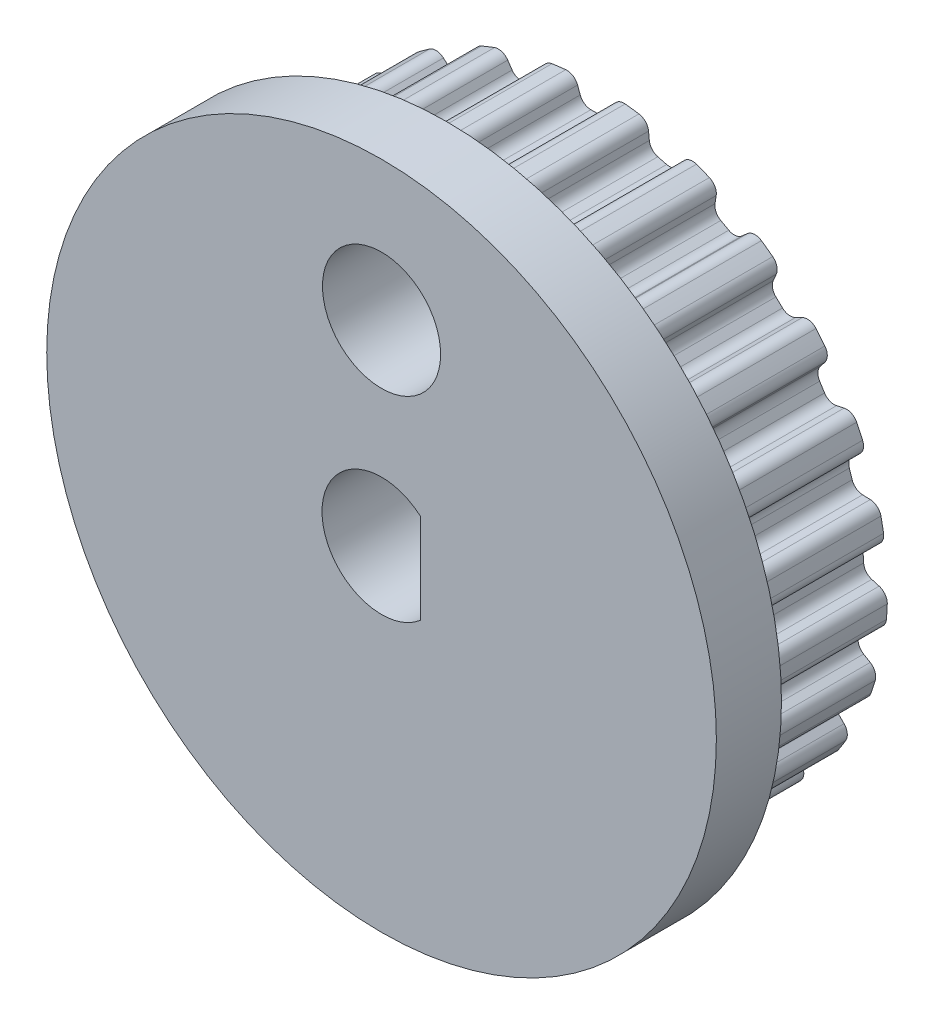
from build123d import *

# Parameters (mm, degrees)
BOSS_EXTRUDE1_DEPTH = 4.000000001
SKETCH2_R           = 9
BOSS_EXTRUDE2_DEPTH = 1.75
SKETCH4_W           = 4.5
SKETCH4_H           = 4.5
BOSS_EXTRUDE3_DEPTH = 1.75
CUT_EXTRUDE2_DEPTH  = 8.500000001
SKETCH5_R           = 1.5875
CUT_EXTRUDE3_DEPTH  = 8.500000001


with BuildPart() as part:
    # Sketch1 → Boss-Extrude1 (new body)
    with BuildSketch(Plane(origin=(0, 0, -5.299999992), x_dir=(-1, 0, 0), z_dir=(0, 0, -1))):
        with BuildLine():
            Line((-2.770498963, -6.663011251), (-2.541538281, -6.753663208))
            ThreePointArc((-2.541538281, -6.753663208), (-2.399281022, -6.869272551), (-2.349061487, -7.04556959))
            Line((-2.349061487, -7.04556959), (-2.354850369, -7.252814955))
            ThreePointArc((-2.354850369, -7.252814955), (-2.295763451, -7.44184279), (-2.13298896, -7.55465791))
            ThreePointArc((-2.13298896, -7.55465791), (-1.9522156, -7.60337769), (-1.770331764, -7.647772452))
            ThreePointArc((-1.770331764, -7.647772452), (-1.573342284, -7.627329016), (-1.430499165, -7.490147994))
            Line((-1.430499165, -7.490147994), (-1.335730789, -7.305748684))
            ThreePointArc((-1.335730789, -7.305748684), (-1.206791332, -7.175451857), (-1.026435123, -7.142675578))
            Line((-1.026435123, -7.142675578), (-0.782123427, -7.173539321))
            ThreePointArc((-0.782123427, -7.173539321), (-0.615584572, -7.250138629), (-0.523099481, -7.408407869))
            Line((-0.523099481, -7.408407869), (-0.477166643, -7.610581923))
            ThreePointArc((-0.477166643, -7.610581923), (-0.372926733, -7.778976773), (-0.187210126, -7.847767225))
            ThreePointArc((-0.187210126, -7.847767225), (1.8e-08, -7.849999876), (0.187210163, -7.847767225))
            ThreePointArc((0.187210163, -7.847767225), (0.372926769, -7.778976773), (0.477166678, -7.610581924))
            Line((0.477166678, -7.610581924), (0.523099513, -7.408407881))
            ThreePointArc((0.523099513, -7.408407881), (0.615584602, -7.250138644), (0.782123452, -7.173539334))
            Line((0.782123452, -7.173539334), (1.026435157, -7.142675586))
            ThreePointArc((1.026435157, -7.142675586), (1.206791369, -7.175451863), (1.33573083, -7.305748691))
            Line((1.33573083, -7.305748691), (1.430499202, -7.490147994))
            ThreePointArc((1.430499202, -7.490147994), (1.573342321, -7.627329016), (1.770331801, -7.647772452))
            ThreePointArc((1.770331801, -7.647772452), (1.952215637, -7.60337769), (2.132988997, -7.55465791))
            ThreePointArc((2.132988997, -7.55465791), (2.295763494, -7.441842782), (2.354850406, -7.252814935))
            Line((2.354850406, -7.252814935), (2.349061514, -7.045569606))
            ThreePointArc((2.349061514, -7.045569606), (2.399281043, -6.869272556), (2.541538305, -6.753663204))
            Line((2.541538305, -6.753663204), (2.770498989, -6.663011244))
            ThreePointArc((2.770498989, -6.663011244), (2.953340111, -6.64990502), (3.11063221, -6.744042389))
            Line((3.11063221, -6.744042389), (3.248281539, -6.899080544))
            ThreePointArc((3.248281539, -6.899080544), (3.42075251, -6.996428125), (3.616637274, -6.967240001))
            ThreePointArc((3.616637274, -6.967240001), (3.781766365, -6.879007311), (3.94474428, -6.786861647))
            ThreePointArc((3.94474428, -6.786861647), (4.074348937, -6.637110438), (4.084570207, -6.439326927))
            Line((4.084570207, -6.439326927), (4.027423359, -6.240032231))
            ThreePointArc((4.027423359, -6.240032231), (4.032221853, -6.056784784), (4.141258967, -5.909429568))
            Line((4.141258967, -5.909429568), (4.340482222, -5.76468539))
            ThreePointArc((4.340482222, -5.76468539), (4.514319692, -5.706520185), (4.690081199, -5.758583127))
            Line((4.690081199, -5.758583127), (4.861962355, -5.874518455))
            ThreePointArc((4.861962355, -5.874518455), (5.053224205, -5.925915922), (5.235696117, -5.848930236))
            ThreePointArc((5.235696117, -5.848930236), (5.373694804, -5.722403597), (5.50863678, -5.592621893))
            ThreePointArc((5.50863678, -5.592621893), (5.596928058, -5.415344021), (5.557641445, -5.221232311))
            Line((5.557641445, -5.221232311), (5.452727407, -5.042410696))
            ThreePointArc((5.452727407, -5.042410696), (5.411803358, -4.863726966), (5.480769122, -4.693884755))
            Line((5.480769122, -4.693884755), (5.637737001, -4.504143178))
            ThreePointArc((5.637737001, -4.504143178), (5.791647936, -4.404573728), (5.974835084, -4.411290898))
            Line((5.974835084, -4.411290898), (6.170148257, -4.480838795))
            ThreePointArc((6.170148257, -4.480838795), (6.368183279, -4.483056618), (6.525776925, -4.363110665))
            ThreePointArc((6.525776925, -4.363110665), (6.627974228, -4.206240225), (6.726401351, -4.046977156))
            ThreePointArc((6.726401351, -4.046977156), (6.767831585, -3.853311658), (6.681505632, -3.675068511))
            Line((6.681505632, -3.675068511), (6.535416505, -3.527955909))
            ThreePointArc((6.535416505, -3.527955909), (6.451341341, -3.365063263), (6.475902375, -3.183405886))
            Line((6.475902375, -3.183405886), (6.580751989, -2.960589078))
            ThreePointArc((6.580751989, -2.960589078), (6.705065617, -2.825871679), (6.884168106, -2.78682102))
            Line((6.884168106, -2.78682102), (7.090641024, -2.805611531))
            ThreePointArc((7.090641024, -2.805611531), (7.283005966, -2.758510368), (7.405819176, -2.603140787))
            ThreePointArc((7.405819176, -2.603140787), (7.46579367, -2.425783284), (7.52152141, -2.247045927))
            ThreePointArc((7.52152141, -2.247045927), (7.513487384, -2.049161499), (7.385546242, -1.897986579))
            Line((7.385546242, -1.897986579), (7.207461372, -1.791826697))
            ThreePointArc((7.207461372, -1.791826697), (7.085517816, -1.654960251), (7.06413088, -1.472901871))
            Line((7.06413088, -1.472901871), (7.110274201, -1.231010202))
            ThreePointArc((7.110274201, -1.231010202), (7.197179435, -1.069609688), (7.360943563, -0.987244916))
            Line((7.360943563, -0.987244916), (7.565602753, -0.95409736))
            ThreePointArc((7.565602753, -0.95409736), (7.740210608, -0.86063675), (7.820526569, -0.679605993))
            ThreePointArc((7.820526569, -0.679605993), (7.834509837, -0.492905448), (7.844036614, -0.305924525))
            ThreePointArc((7.844036614, -0.305924525), (7.78704314, -0.116254991), (7.625525841, -0.001647178))
            Line((7.625525841, -0.001647178), (7.426634918, 0.056889606))
            ThreePointArc((7.426634918, 0.056889606), (7.274485151, 0.15913001), (7.208494045, 0.330149967))
            Line((7.208494045, 0.330149967), (7.193031666, 0.575917525))
            ThreePointArc((7.193031666, 0.575917525), (7.237067931, 0.753859804), (7.375203825, 0.874363422))
            Line((7.375203825, 0.874363422), (7.565189822, 0.957366261))
            ThreePointArc((7.565189822, 0.957366261), (7.711069345, 1.091313843), (7.743841513, 1.286630957))
            ThreePointArc((7.743841513, 1.286630957), (7.710954935, 1.470943449), (7.673682148, 1.654419227))
            ThreePointArc((7.673682148, 1.654419227), (7.571310327, 1.82395625), (7.386365577, 1.894795725))
            Line((7.386365577, 1.894795725), (7.179165715, 1.902031296))
            ThreePointArc((7.179165715, 1.902031296), (7.006369859, 1.963221511), (6.899921047, 2.112457233))
            Line((6.899921047, 2.112457233), (6.823824527, 2.346658216))
            ThreePointArc((6.823824527, 2.346658216), (6.822224861, 2.529961496), (6.926052937, 2.681032281))
            Line((6.926052937, 2.681032281), (7.089428199, 2.808675019))
            ThreePointArc((7.089428199, 2.808675019), (7.197413244, 2.974693155), (7.180582424, 3.172024133))
            ThreePointArc((7.180582424, 3.172024133), (7.10289238, 3.342367562), (7.02116201, 3.510809758))
            ThreePointArc((7.02116201, 3.510809758), (6.879844249, 3.649561624), (6.683092823, 3.67218166))
            Line((6.683092823, 3.67218166), (6.480603082, 3.627661399))
            ThreePointArc((6.480603082, 3.627661399), (6.298018541, 3.643956633), (6.157800604, 3.762031099))
            Line((6.157800604, 3.762031099), (6.025851382, 3.969949803))
            ThreePointArc((6.025851382, 3.969949803), (5.978716304, 4.147096461), (6.041712663, 4.319242076))
            Line((6.041712663, 4.319242076), (6.168211718, 4.483504424))
            ThreePointArc((6.168211718, 4.483504424), (6.231517191, 4.671161588), (6.166140924, 4.858107403))
            ThreePointArc((6.166140924, 4.858107403), (6.048528974, 5.003778443), (5.927476451, 5.146603192))
            ThreePointArc((5.927476451, 5.146603192), (5.756092274, 5.245851614), (5.559896791, 5.218830927))
            Line((5.559896791, 5.218830927), (5.374840317, 5.125352196))
            ThreePointArc((5.374840317, 5.125352196), (5.193939557, 5.095728573), (5.028762915, 5.175222731))
            Line((5.028762915, 5.175222731), (4.849251859, 5.343794843))
            ThreePointArc((4.849251859, 5.343794843), (4.759543042, 5.50365408), (4.777749369, 5.686057966))
            Line((4.777749369, 5.686057966), (4.859423838, 5.876618788))
            ThreePointArc((4.859423838, 5.876618788), (4.874072, 6.074123776), (4.764258119, 6.238937914))
            ThreePointArc((4.764258119, 6.238937914), (4.614114251, 6.350783528), (4.461345743, 6.459016637))
            ThreePointArc((4.461345743, 6.459016637), (4.270663826, 6.512525475), (4.087351951, 6.437561846))
            Line((4.087351951, 6.437561846), (3.931356637, 6.300998273))
            ThreePointArc((3.931356637, 6.300998273), (3.763506296, 6.227317127), (3.583749576, 6.263236065))
            Line((3.583749576, 6.263236065), (3.367956, 6.381869588))
            ThreePointArc((3.367956, 6.381869588), (3.241310171, 6.514396877), (3.213582509, 6.69559794))
            Line((3.213582509, 6.69559794), (3.245300476, 6.900483573))
            ThreePointArc((3.245300476, 6.900483573), (3.210370947, 7.095426422), (3.063019466, 7.227753016))
            ThreePointArc((3.063019466, 7.227753016), (2.889777761, 7.298745536), (2.714892269, 7.365586324))
            ThreePointArc((2.714892269, 7.365586324), (2.516893872, 7.369993419), (2.357983776, 7.251797104))
            Line((2.357983776, 7.251797104), (2.240851316, 7.080729469))
            ThreePointArc((2.240851316, 7.080729469), (2.096598059, 6.967620471), (1.913556053, 6.957707268))
            Line((1.913556053, 6.957707268), (1.675039076, 7.018948014))
            ThreePointArc((1.675039076, 7.018948014), (1.51941385, 7.115816183), (1.447494432, 7.284428907))
            Line((1.447494432, 7.284428907), (1.427262951, 7.490765576))
            ThreePointArc((1.427262951, 7.490765576), (1.344950483, 7.670897333), (1.169320022, 7.762421829))
            ThreePointArc((1.169320022, 7.762421829), (0.983865903, 7.788100529), (0.797852133, 7.809349137))
            ThreePointArc((0.797852133, 7.809349137), (0.604978216, 7.764377573), (0.480454802, 7.610375273))
            Line((0.480454802, 7.610375273), (0.409545077, 7.415552396))
            ThreePointArc((0.409545077, 7.415552396), (0.297952865, 7.270122591), (0.123126767, 7.215000134))
            Line((0.123126767, 7.215000134), (-0.12312673, 7.215000134))
            ThreePointArc((-0.12312673, 7.215000134), (-0.297952827, 7.270122591), (-0.409545038, 7.415552395))
            Line((-0.409545038, 7.415552395), (-0.480454763, 7.610375271))
            ThreePointArc((-0.480454763, 7.610375271), (-0.604978178, 7.764377573), (-0.797852096, 7.809349137))
            ThreePointArc((-0.797852096, 7.809349137), (-0.983865866, 7.788100529), (-1.169319985, 7.762421829))
            ThreePointArc((-1.169319985, 7.762421829), (-1.344950446, 7.670897333), (-1.427262914, 7.490765576))
            Line((-1.427262914, 7.490765576), (-1.447494396, 7.284428898))
            ThreePointArc((-1.447494396, 7.284428898), (-1.519413814, 7.115816175), (-1.67503904, 7.018948005))
            Line((-1.67503904, 7.018948005), (-1.913556012, 6.957707261))
            ThreePointArc((-1.913556012, 6.957707261), (-2.096598018, 6.967620464), (-2.240851274, 7.080729462))
            Line((-2.240851274, 7.080729462), (-2.357983739, 7.251797104))
            ThreePointArc((-2.357983739, 7.251797104), (-2.516893836, 7.369993419), (-2.714892233, 7.365586324))
            ThreePointArc((-2.714892233, 7.365586324), (-2.889777725, 7.298745536), (-3.063019429, 7.227753016))
            ThreePointArc((-3.063019429, 7.227753016), (-3.210370911, 7.095426422), (-3.24530044, 6.900483573))
            Line((-3.24530044, 6.900483573), (-3.21358247, 6.695597928))
            ThreePointArc((-3.21358247, 6.695597928), (-3.241310132, 6.514396865), (-3.367955962, 6.381869576))
            Line((-3.367955962, 6.381869576), (-3.58374953, 6.263236057))
            ThreePointArc((-3.58374953, 6.263236057), (-3.76350625, 6.227317119), (-3.931356591, 6.300998266))
            Line((-3.931356591, 6.300998266), (-4.087351915, 6.437561846))
            ThreePointArc((-4.087351915, 6.437561846), (-4.27066379, 6.512525475), (-4.461345707, 6.459016637))
            ThreePointArc((-4.461345707, 6.459016637), (-4.614114214, 6.350783528), (-4.764258082, 6.238937914))
            ThreePointArc((-4.764258082, 6.238937914), (-4.874071964, 6.074123776), (-4.859423801, 5.876618788))
            Line((-4.859423801, 5.876618788), (-4.77774934, 5.686057982))
            ThreePointArc((-4.77774934, 5.686057982), (-4.759543013, 5.503654097), (-4.849251829, 5.343794859))
            Line((-4.849251829, 5.343794859), (-5.028762894, 5.17522274))
            ThreePointArc((-5.028762894, 5.17522274), (-5.193939536, 5.095728582), (-5.374840296, 5.125352204))
            Line((-5.374840296, 5.125352204), (-5.559896754, 5.218830927))
            ThreePointArc((-5.559896754, 5.218830927), (-5.756092237, 5.245851614), (-5.927476414, 5.146603192))
            ThreePointArc((-5.927476414, 5.146603192), (-6.048528938, 5.003778443), (-6.166140887, 4.858107403))
            ThreePointArc((-6.166140887, 4.858107403), (-6.231517154, 4.671161588), (-6.168211682, 4.483504424))
            Line((-6.168211682, 4.483504424), (-6.04171263, 4.31924208))
            ThreePointArc((-6.04171263, 4.31924208), (-5.978716271, 4.147096465), (-6.025851349, 3.969949807))
            Line((-6.025851349, 3.969949807), (-6.157800573, 3.7620311))
            ThreePointArc((-6.157800573, 3.7620311), (-6.29801851, 3.643956634), (-6.480603051, 3.6276614))
            Line((-6.480603051, 3.6276614), (-6.683092787, 3.67218166))
            ThreePointArc((-6.683092787, 3.67218166), (-6.879844213, 3.649561624), (-7.021161973, 3.510809758))
            ThreePointArc((-7.021161973, 3.510809758), (-7.102892344, 3.342367562), (-7.180582387, 3.172024133))
            ThreePointArc((-7.180582387, 3.172024133), (-7.197413207, 2.974693155), (-7.089428162, 2.808675019))
            Line((-7.089428162, 2.808675019), (-6.926052897, 2.681032278))
            ThreePointArc((-6.926052897, 2.681032278), (-6.822224821, 2.529961494), (-6.823824488, 2.346658214))
            Line((-6.823824488, 2.346658214), (-6.899921006, 2.112457233))
            ThreePointArc((-6.899921006, 2.112457233), (-7.006369819, 1.963221511), (-7.179165675, 1.902031296))
            Line((-7.179165675, 1.902031296), (-7.386365541, 1.894795725))
            ThreePointArc((-7.386365541, 1.894795725), (-7.571310291, 1.82395625), (-7.673682111, 1.654419227))
            ThreePointArc((-7.673682111, 1.654419227), (-7.710954911, 1.470943384), (-7.743841498, 1.286630826))
            ThreePointArc((-7.743841498, 1.286630826), (-7.711069328, 1.091313715), (-7.565189806, 0.957366136))
            Line((-7.565189806, 0.957366136), (-7.375203809, 0.874363296))
            ThreePointArc((-7.375203809, 0.874363296), (-7.237067915, 0.753859678), (-7.19303165, 0.5759174))
            Line((-7.19303165, 0.5759174), (-7.20849403, 0.330149843))
            ThreePointArc((-7.20849403, 0.330149843), (-7.274485135, 0.159129886), (-7.426634903, 0.056889483))
            Line((-7.426634903, 0.056889483), (-7.6255258, -0.001647294))
            ThreePointArc((-7.6255258, -0.001647294), (-7.7870431, -0.116255109), (-7.844036572, -0.305924646))
            ThreePointArc((-7.844036572, -0.305924646), (-7.834509796, -0.492905509), (-7.820526532, -0.679605993))
            ThreePointArc((-7.820526532, -0.679605993), (-7.740210572, -0.86063675), (-7.565602716, -0.95409736))
            Line((-7.565602716, -0.95409736), (-7.360943526, -0.987244916))
            ThreePointArc((-7.360943526, -0.987244916), (-7.197179397, -1.069609688), (-7.110274163, -1.231010202))
            Line((-7.110274163, -1.231010202), (-7.064130842, -1.47290187))
            ThreePointArc((-7.064130842, -1.47290187), (-7.085517778, -1.654960251), (-7.207461334, -1.791826697))
            Line((-7.207461334, -1.791826697), (-7.385546205, -1.897986579))
            ThreePointArc((-7.385546205, -1.897986579), (-7.513487347, -2.049161499), (-7.521521373, -2.247045927))
            ThreePointArc((-7.521521373, -2.247045927), (-7.465793634, -2.425783284), (-7.405819139, -2.603140787))
            ThreePointArc((-7.405819139, -2.603140787), (-7.28300593, -2.758510368), (-7.090640987, -2.805611531))
            Line((-7.090640987, -2.805611531), (-6.884168079, -2.786821021))
            ThreePointArc((-6.884168079, -2.786821021), (-6.705065589, -2.82587168), (-6.580751962, -2.960589079))
            Line((-6.580751962, -2.960589079), (-6.475902344, -3.183405892))
            ThreePointArc((-6.475902344, -3.183405892), (-6.451341311, -3.36506327), (-6.535416475, -3.527955915))
            Line((-6.535416475, -3.527955915), (-6.681505595, -3.675068511))
            ThreePointArc((-6.681505595, -3.675068511), (-6.767831549, -3.853311658), (-6.726401314, -4.046977156))
            ThreePointArc((-6.726401314, -4.046977156), (-6.627974191, -4.206240225), (-6.525776888, -4.363110665))
            ThreePointArc((-6.525776888, -4.363110665), (-6.368183242, -4.483056618), (-6.17014822, -4.480838795))
            Line((-6.17014822, -4.480838795), (-5.974835047, -4.411290898))
            ThreePointArc((-5.974835047, -4.411290898), (-5.791647899, -4.404573728), (-5.637736963, -4.504143178))
            Line((-5.637736963, -4.504143178), (-5.480769085, -4.693884754))
            ThreePointArc((-5.480769085, -4.693884754), (-5.411803321, -4.863726965), (-5.45272737, -5.042410695))
            Line((-5.45272737, -5.042410695), (-5.557641409, -5.221232311))
            ThreePointArc((-5.557641409, -5.221232311), (-5.596928022, -5.415344021), (-5.508636743, -5.592621893))
            ThreePointArc((-5.508636743, -5.592621893), (-5.373694767, -5.722403597), (-5.235696081, -5.848930236))
            ThreePointArc((-5.235696081, -5.848930236), (-5.053224168, -5.925915922), (-4.861962318, -5.874518455))
            Line((-4.861962318, -5.874518455), (-4.690081172, -5.758583134))
            ThreePointArc((-4.690081172, -5.758583134), (-4.514319665, -5.706520192), (-4.340482195, -5.764685397))
            Line((-4.340482195, -5.764685397), (-4.141258934, -5.909429579))
            ThreePointArc((-4.141258934, -5.909429579), (-4.032221819, -6.056784796), (-4.027423326, -6.240032243))
            Line((-4.027423326, -6.240032243), (-4.08457017, -6.439326927))
            ThreePointArc((-4.08457017, -6.439326927), (-4.0743489, -6.637110438), (-3.944744243, -6.786861647))
            ThreePointArc((-3.944744243, -6.786861647), (-3.781766328, -6.879007311), (-3.616637238, -6.967240001))
            ThreePointArc((-3.616637238, -6.967240001), (-3.420752473, -6.996428125), (-3.248281502, -6.899080544))
            Line((-3.248281502, -6.899080544), (-3.110632181, -6.744042398))
            ThreePointArc((-3.110632181, -6.744042398), (-2.953340083, -6.649905029), (-2.770498963, -6.663011251))
        make_face()
    extrude(amount=-BOSS_EXTRUDE1_DEPTH)

    # Sketch2 → Boss-Extrude2 (add)
    with BuildSketch(Plane.XY.offset(-1.299999991)):
        Circle(SKETCH2_R)
    extrude(amount=BOSS_EXTRUDE2_DEPTH)

    # Sketch4 → Boss-Extrude3 (add)
    with BuildSketch(Plane(origin=(0, 0, -5.299999992), x_dir=(-1, 0, 0), z_dir=(0, 0, -1))):
        Rectangle(SKETCH4_W, SKETCH4_H)
    extrude(amount=BOSS_EXTRUDE3_DEPTH)

    # Sketch3 → Cut-Extrude2 (cut, through all)
    with BuildSketch(Plane.XY.offset(0.450000009)):
        with BuildLine():
            Line((1.041610738, 1.214515158), (1.041610738, -1.214515158))
            ThreePointArc((1.041610738, -1.214515158), (-1.6, 0), (1.041610738, 1.214515158))
        make_face()
    extrude(amount=-CUT_EXTRUDE2_DEPTH, mode=Mode.SUBTRACT)

    # Sketch5 → Cut-Extrude3 (cut, through all)
    with BuildSketch(Plane.XY.offset(0.450000009)):
        with Locations((0, 5.25)):
            Circle(SKETCH5_R)
    extrude(amount=-CUT_EXTRUDE3_DEPTH, mode=Mode.SUBTRACT)


solid = part.part
